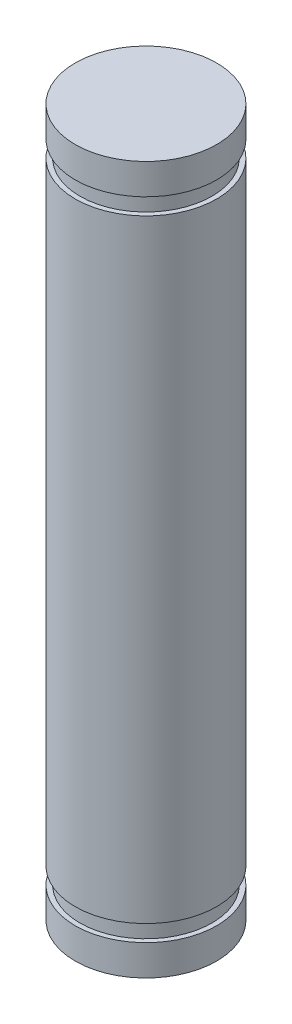
from build123d import *


with BuildPart() as part:
    # 草图1 → 旋转1 (revolve)
    with BuildSketch(Plane.XY):
        Polygon((0, -15), (3, -15), (3, -13.7), (2.8, -13.7), (2.8, -13), (3, -13), (3, 13), (2.8, 13), (2.8, 13.7), (3, 13.7), (3, 15), (0, 15), align=None)
    revolve(axis=Axis((0, 15, 0), (0, -1, 0)))


solid = part.part
